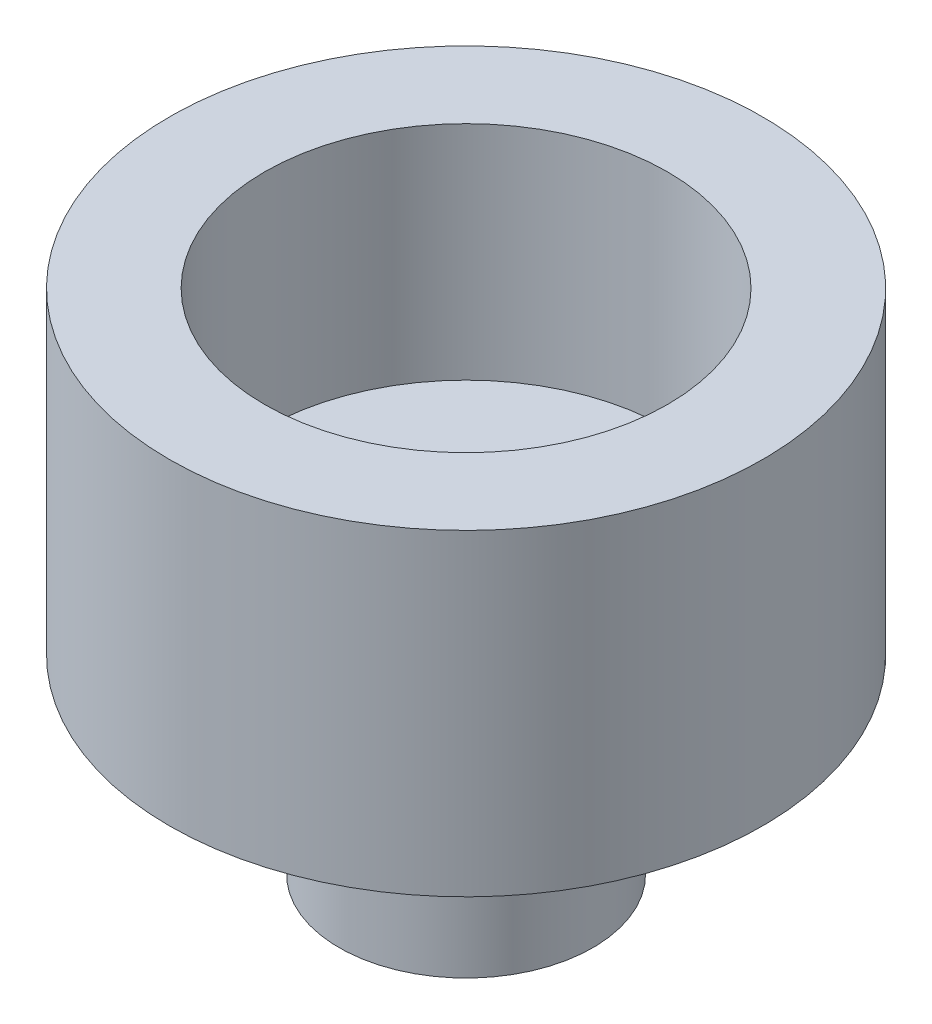
from build123d import *

# Parameters (mm, degrees)
SKETCH1_R           = 9.35
BOSS_EXTRUDE1_DEPTH = 10
SKETCH2_R           = 6.35
CUT_EXTRUDE1_DEPTH  = 7
SKETCH3_R           = 4
BOSS_EXTRUDE2_DEPTH = 6


with BuildPart() as part:
    # Sketch1 → Boss-Extrude1 (new body)
    with BuildSketch(Plane(origin=(0, 0, 0), x_dir=(1, 0, 0), z_dir=(0, 1, 0))):
        Circle(SKETCH1_R)
    extrude(amount=BOSS_EXTRUDE1_DEPTH)

    # Sketch2 → Cut-Extrude1 (cut)
    with BuildSketch(Plane(origin=(0, 10, 0), x_dir=(1, 0, 0), z_dir=(0, 1, 0))):
        Circle(SKETCH2_R)
    extrude(amount=-CUT_EXTRUDE1_DEPTH, mode=Mode.SUBTRACT)

    # Sketch3 → Boss-Extrude2 (add)
    with BuildSketch(Plane.XZ):
        Circle(SKETCH3_R)
    extrude(amount=BOSS_EXTRUDE2_DEPTH)


solid = part.part
